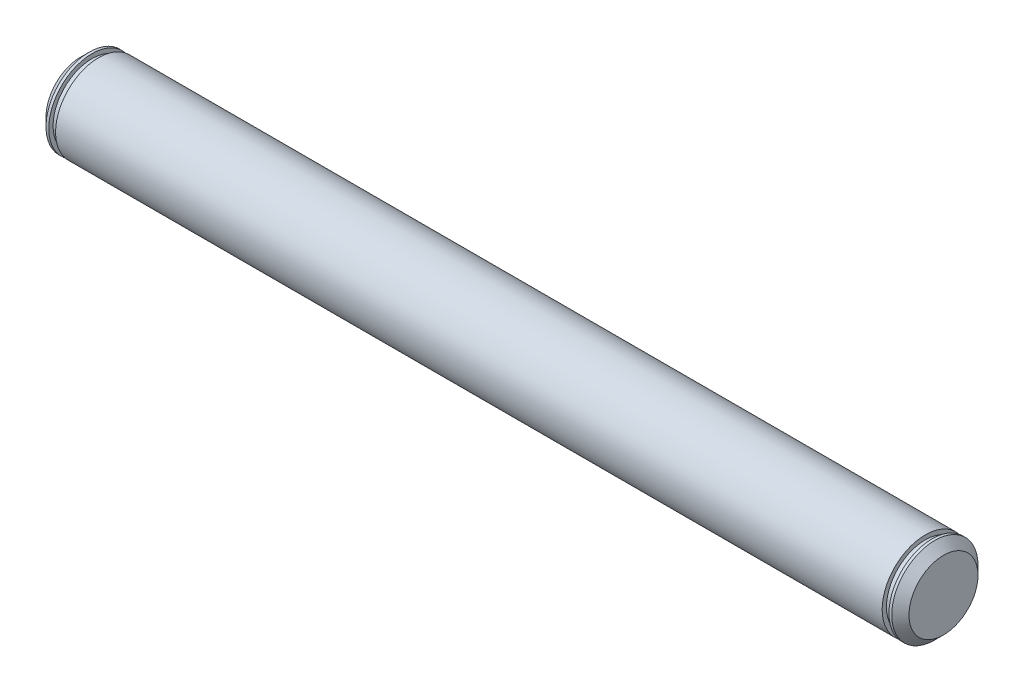
from build123d import *

# Parameters (mm, degrees)
SKETCH2_R           = 6.35
EXTRUDE1_DEPTH      = 63.5
EXTRUDE1_DEPTH_BACK = 63.5
CHAMFER1_SIZE       = 1.27
CUT_EXTRUDE1_START  = 0.5
SKETCH3_R           = 6.35
SKETCH3_R_2         = 5.715
CUT_EXTRUDE1_DEPTH  = 1


with BuildPart() as part:
    # Sketch2 → Extrude1 (new body, two sides)
    with BuildSketch(Plane(origin=(0, 0, 0), x_dir=(0, 0, -1), z_dir=(1, 0, 0))) as extrude1_sk:
        Circle(SKETCH2_R)
    extrude(amount=EXTRUDE1_DEPTH)
    extrude(extrude1_sk.sketch, amount=-EXTRUDE1_DEPTH_BACK)

    # Chamfer1
    chamfer1_edges = [part.edges().sort_by_distance(p)[0] for p in [
        (-63.5, 0, 6.35),
        (63.5, 0, 6.35),
    ]]
    chamfer(chamfer1_edges, length=CHAMFER1_SIZE)

    # Sketch3 → Cut-Extrude1 (cut)
    with BuildSketch(Plane.ZY.offset(60.323942702).offset(CUT_EXTRUDE1_START)):
        Circle(SKETCH3_R)
        Circle(SKETCH3_R_2, mode=Mode.SUBTRACT)
    cut_extrude1 = extrude(amount=CUT_EXTRUDE1_DEPTH, mode=Mode.SUBTRACT)

    # Mirror1: Cut-Extrude1 across plane
    add(cut_extrude1.mirror(Plane(origin=(0, 0, 0), x_dir=(0, 0, 1), z_dir=(1, 0, 0))), mode=Mode.SUBTRACT)


solid = part.part
